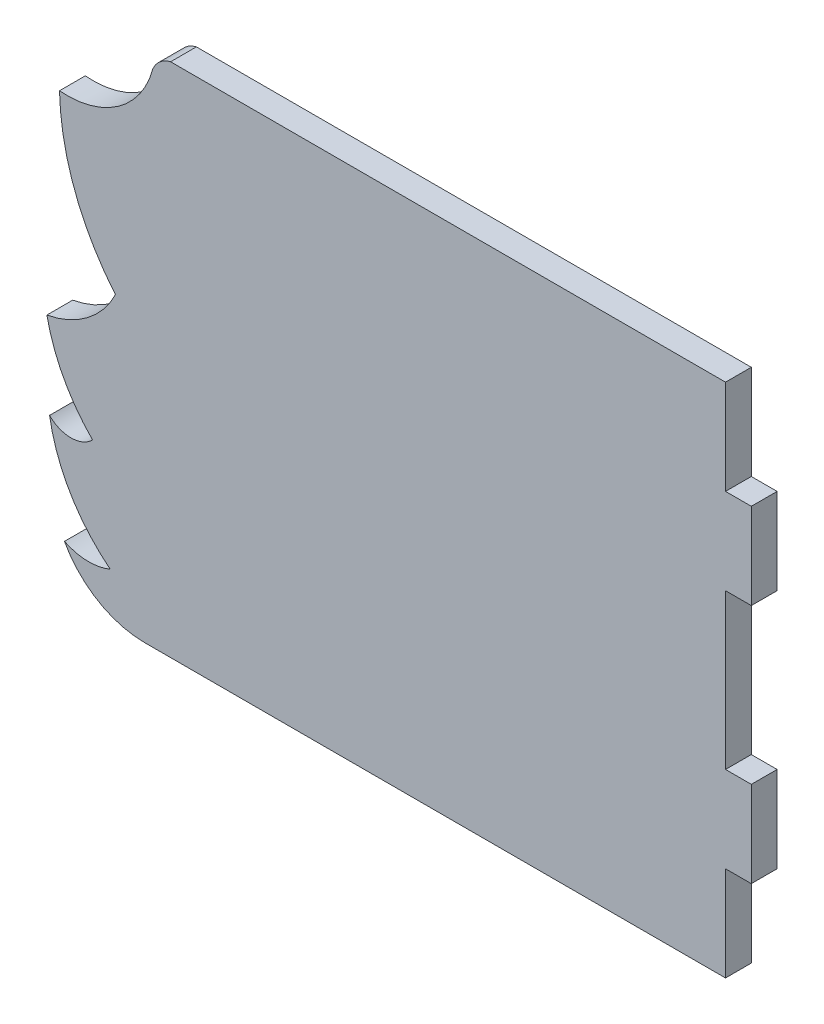
from build123d import *

# Parameters (mm, degrees)
SALIENTE_EXTRUIR1_DEPTH = 3


with BuildPart() as part:
    # Model → Saliente-Extruir1 (new body)
    with BuildSketch(Plane.XY):
        with BuildLine():
            Line((96.785797009, 36.015840028), (93.785797009, 36.015840028))
            Line((93.785797009, 36.015840028), (93.785797009, 47.015840028))
            Line((93.785797009, 47.015840028), (31.751178944, 47.015840028))
            Line((31.751178944, 47.015840028), (29.260721948, 47.015840028))
            ThreePointArc((29.260721948, 47.015840028), (28.01691559, 46.383744396), (27.193529557, 45.257407597))
            ThreePointArc((27.193529557, 45.257407597), (23.155632663, 39.471985621), (16.34281865, 37.638605137))
            ThreePointArc((16.34281865, 37.638605137), (18.127374477, 28.444980745), (22.850598251, 20.358045222))
            ThreePointArc((22.850598251, 20.358045222), (19.57702332, 16.398637511), (14.878347932, 14.321222809))
            ThreePointArc((14.878347932, 14.321222809), (16.813155193, 8.973175992), (20.188286302, 4.395668604))
            ThreePointArc((20.188286302, 4.395668604), (17.693087489, 3.34861877), (15.188339451, 4.372614734))
            ThreePointArc((15.188339451, 4.372614734), (17.604909212, -2.266185371), (22.24359433, -7.594982292))
            ThreePointArc((22.24359433, -7.594982292), (19.566527855, -8.089682901), (16.920851616, -7.447958005))
            ThreePointArc((16.920851616, -7.447958005), (20.831880227, -11.496375144), (26.260721948, -12.984159972))
            Line((26.260721948, -12.984159972), (36.41114869, -12.984159972))
            Line((36.41114869, -12.984159972), (93.785797009, -12.984159972))
            Line((93.785797009, -12.984159972), (93.785797009, -1.984159972))
            Line((93.785797009, -1.984159972), (96.785797009, -1.984159972))
            Line((96.785797009, -1.984159972), (96.785797009, 8.015840028))
            Line((96.785797009, 8.015840028), (93.785797009, 8.015840028))
            Line((93.785797009, 8.015840028), (93.785797009, 26.015840028))
            Line((93.785797009, 26.015840028), (96.785797009, 26.015840028))
            Line((96.785797009, 26.015840028), (96.785797009, 36.015840028))
        make_face()
    extrude(amount=SALIENTE_EXTRUIR1_DEPTH)


solid = part.part
